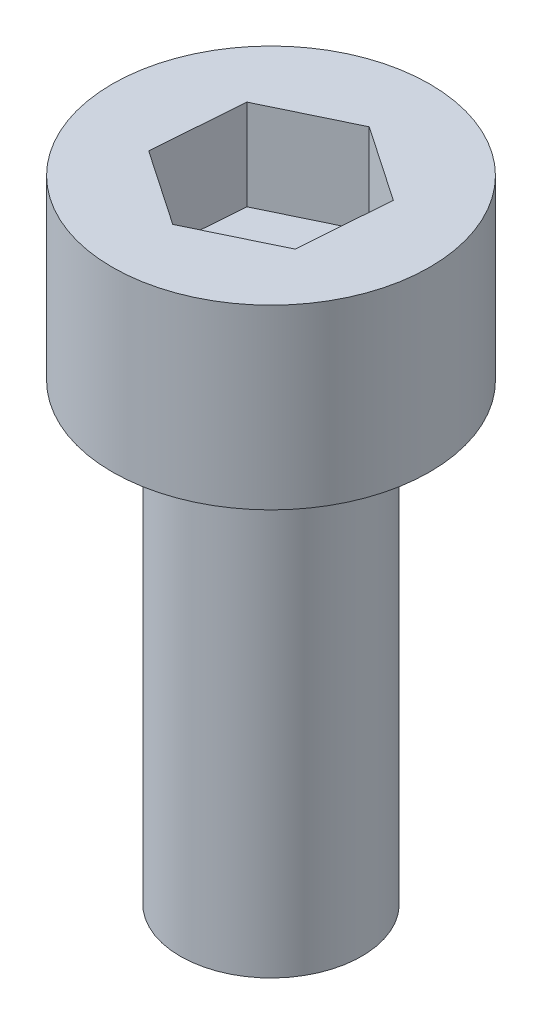
from build123d import *

# Parameters (mm, degrees)
SKETCH_1_R          = 2
EXTRUDE_1_DEPTH     = 10
SKETCH_2_R          = 3.5
EXTRUDE_2_DEPTH     = 3.91
CUT_EXTRUDE_1_DEPTH = 2


with BuildPart() as part:
    # 草图1 → 凸台-拉伸1 (new body)
    with BuildSketch(Plane(origin=(0, 0, 0), x_dir=(1, 0, 0), z_dir=(0, 1, 0))):
        Circle(SKETCH_1_R)
    extrude(amount=EXTRUDE_1_DEPTH)

    # 草图2 → 凸台-拉伸2 (add)
    with BuildSketch(Plane(origin=(0, 10, 0), x_dir=(1, 0, 0), z_dir=(0, 1, 0))):
        Circle(SKETCH_2_R)
    extrude(amount=EXTRUDE_2_DEPTH)

    # 草图3 → 切除-拉伸1 (cut)
    with BuildSketch(Plane(origin=(0, 13.91, 0), x_dir=(1, 0, 0), z_dir=(0, 1, 0))):
        Polygon((1.669374847, -1.13864874), (1.820786158, 0.876396656), (0.151411311, 2.015045396), (-1.669374847, 1.13864874), (-1.820786158, -0.876396656), (-0.151411311, -2.015045396), align=None)
    extrude(amount=-CUT_EXTRUDE_1_DEPTH, mode=Mode.SUBTRACT)


solid = part.part
